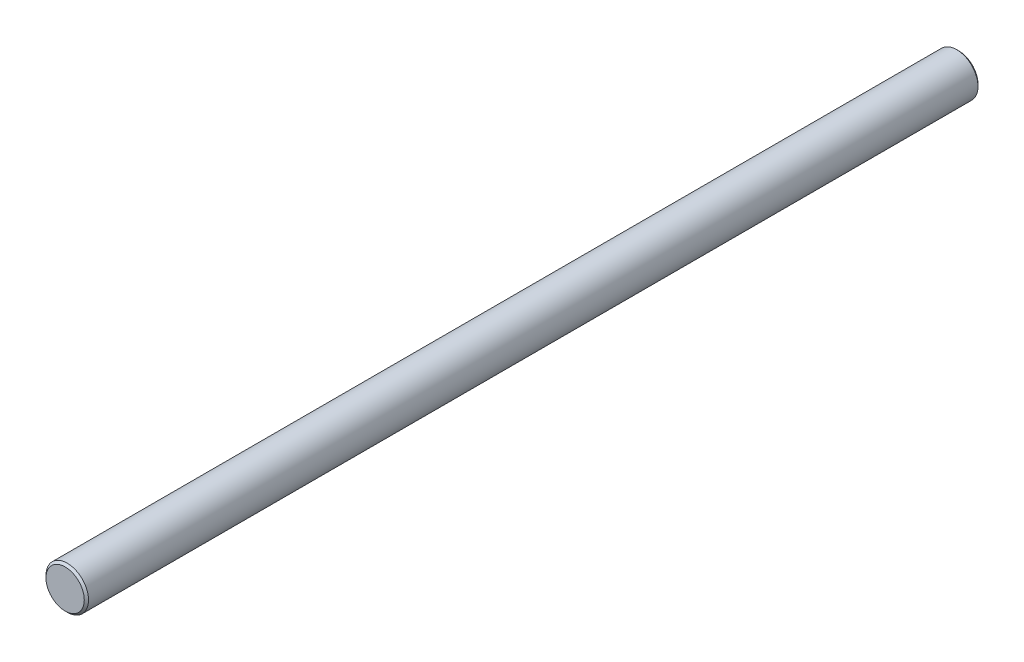
from build123d import *

# Parameters (mm, degrees)
SKETCH1_R           = 5
BOSS_EXTRUDE1_DEPTH = 210
CHAMFER1_SIZE       = 0.5


with BuildPart() as part:
    # Sketch1 → Boss-Extrude1 (new body)
    with BuildSketch(Plane.XY):
        Circle(SKETCH1_R)
    extrude(amount=-BOSS_EXTRUDE1_DEPTH)

    # Chamfer1
    chamfer1_edges = [part.edges().sort_by_distance(p)[0] for p in [
        (-5, 0, 0),
        (-5, 0, -210),
    ]]
    chamfer(chamfer1_edges, length=CHAMFER1_SIZE)


solid = part.part
